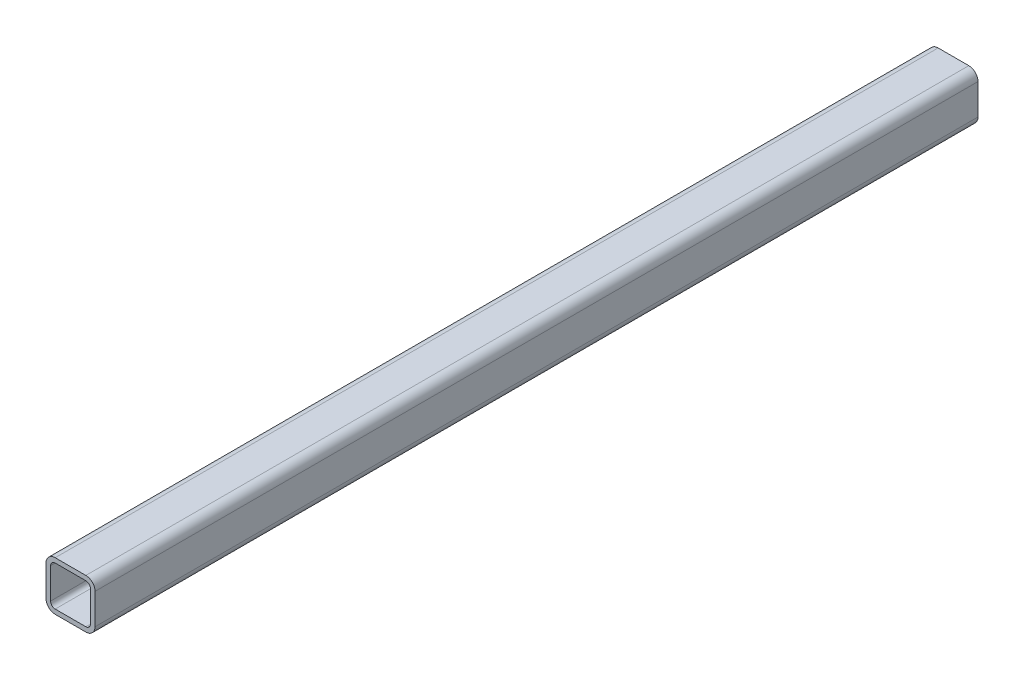
from build123d import *

# Parameters (mm, degrees)
BASETUBES_DEPTH = 457.2


with BuildPart() as part:
    # Sketch1 → BaseTubeS (new body, symmetric)
    with BuildSketch(Plane.XY):
        with BuildLine():
            Line((9.52499175, 0), (41.27496425, 0))
            ThreePointArc((41.27496425, 0), (48.010150507, 2.789805493), (50.799956, 9.52499175))
            Line((50.799956, 9.52499175), (50.799956, 41.27496425))
            ThreePointArc((50.799956, 41.27496425), (48.010150507, 48.010150507), (41.27496425, 50.799956))
            Line((41.27496425, 50.799956), (9.52499175, 50.799956))
            ThreePointArc((9.52499175, 50.799956), (2.789805493, 48.010150507), (0, 41.27496425))
            Line((0, 41.27496425), (0, 9.52499175))
            ThreePointArc((0, 9.52499175), (2.789805493, 2.789805493), (9.52499175, 0))
        make_face()
        with BuildLine():
            Line((9.52499175, 4.762495875), (41.27496425, 4.762495875))
            ThreePointArc((41.27496425, 4.762495875), (44.642557379, 6.157398621), (46.037460125, 9.52499175))
            Line((46.037460125, 9.52499175), (46.037460125, 41.27496425))
            ThreePointArc((46.037460125, 41.27496425), (44.642557379, 44.642557379), (41.27496425, 46.037460125))
            Line((41.27496425, 46.037460125), (9.52499175, 46.037460125))
            ThreePointArc((9.52499175, 46.037460125), (6.157398621, 44.642557379), (4.762495875, 41.27496425))
            Line((4.762495875, 41.27496425), (4.762495875, 9.52499175))
            ThreePointArc((4.762495875, 9.52499175), (6.157398621, 6.157398621), (9.52499175, 4.762495875))
        make_face(mode=Mode.SUBTRACT)
    extrude(amount=BASETUBES_DEPTH, both=True)


solid = part.part
